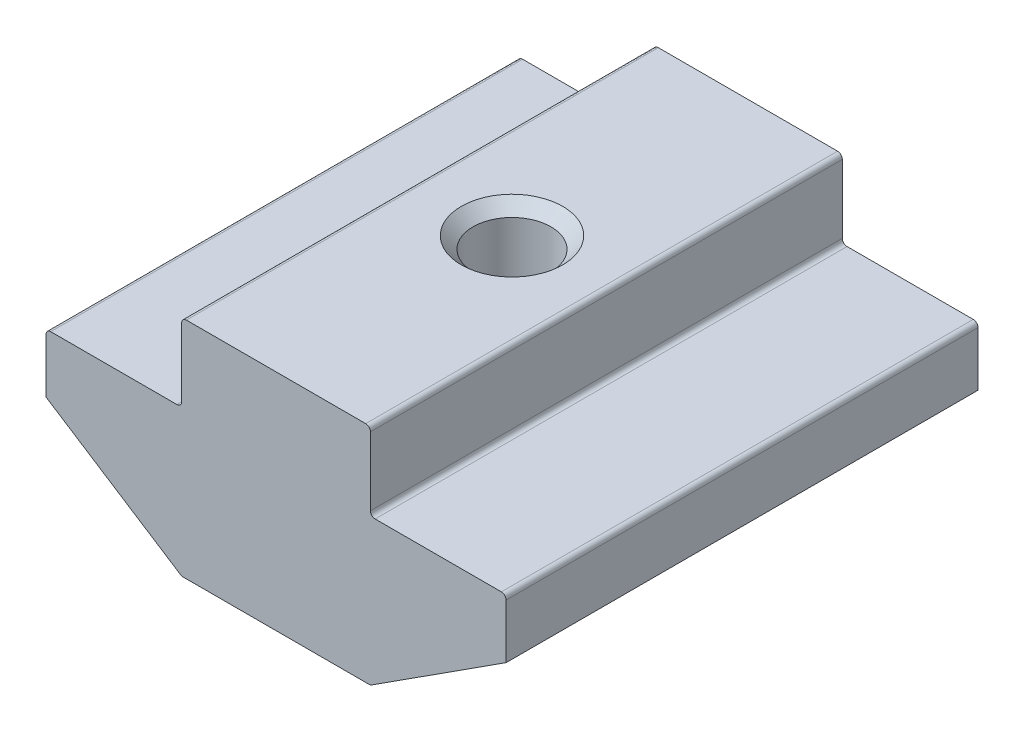
from build123d import *

# Parameters (mm, degrees)
EXTRUDE_1_DEPTH = 10
FILLET_1_R      = 0.2


with BuildPart() as part:
    # Эскиз1 → Бобышка-Вытянуть1 (new body, symmetric)
    with BuildSketch(Plane.XY):
        Polygon((4, 0), (-4, 0), (-4, -3.3), (-9.75, -3.3), (-9.75, -5.8), (-4, -9.5), (4, -9.5), (9.75, -5.8), (9.75, -3.3), (4, -3.3), align=None)
    extrude(amount=EXTRUDE_1_DEPTH, both=True)

    # Эскиз4 → Отверстие обработанное метчиком M43 (revolve, cut)
    with BuildSketch(Plane(origin=(0, 0, 0), x_dir=(0, 0, 1), z_dir=(1, 0, 0))):
        Polygon((0, 0), (0, 9.5), (2.15, 9.5), (1.65, 9), (1.65, 0.5), (2.15, 0), align=None)
    revolve(axis=Axis((0, 6.35, 0), (0, -1, 0)), mode=Mode.SUBTRACT)

    # Скругление1
    fillet_1_edges = [part.edges().sort_by_distance(p)[0] for p in [
        (-4, 0, 0),
        (4, 0, 0),
        (4, -3.3, 0),
        (9.75, -3.3, 0),
        (4, -9.5, 0),
        (-4, -9.5, 0),
        (-9.75, -3.3, 0),
        (-4, -3.3, 0),
    ]]
    fillet(fillet_1_edges, radius=FILLET_1_R)


solid = part.part
